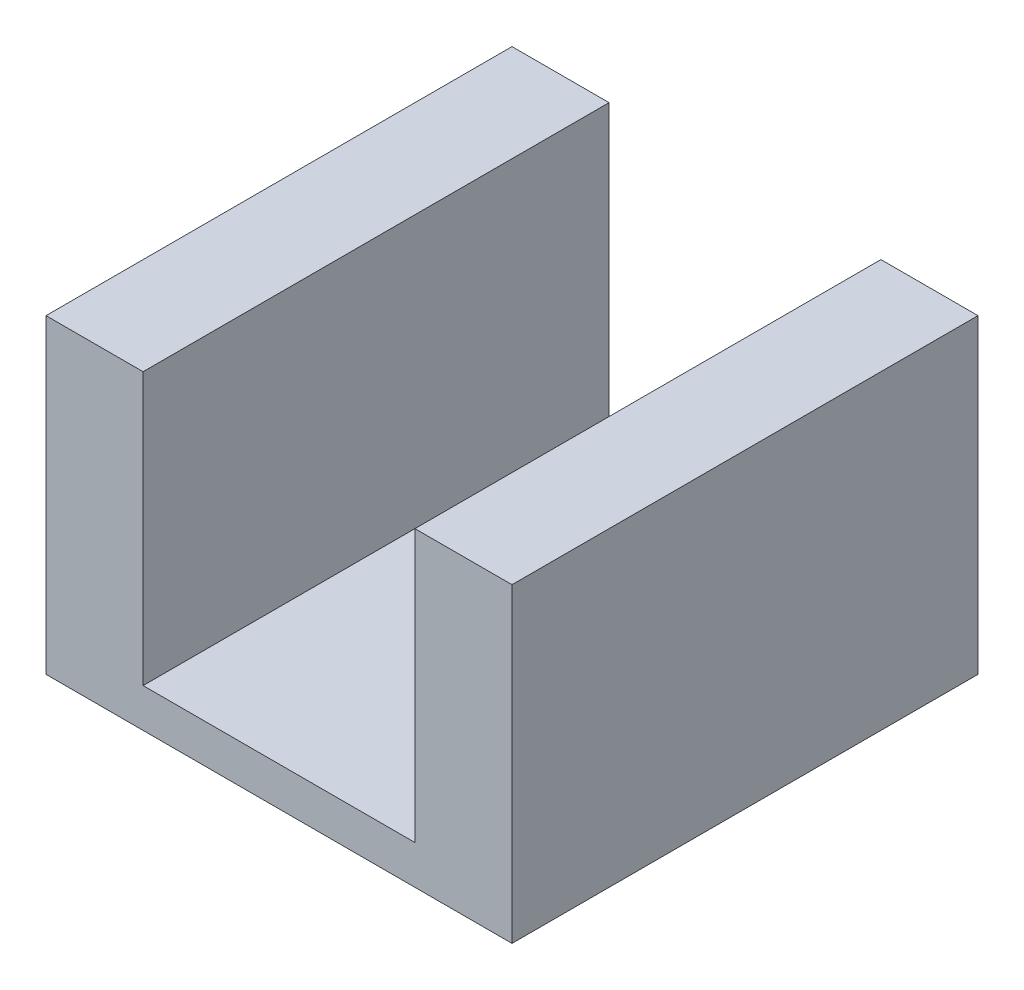
from build123d import *

# Parameters (mm, degrees)
BOSS_EXTRUDE1_DEPTH = 76.2
SKETCH2_R           = 7.9375
CUT_EXTRUDE1_DEPTH  = 7.35


with BuildPart() as part:
    # Sketch1 → Boss-Extrude1 (new body)
    with BuildSketch(Plane.XY):
        Polygon((22.225, 0), (-22.225, 0), (-22.225, 44.45), (-38.1, 44.45), (-38.1, -6.35), (38.1, -6.35), (38.1, 44.45), (22.225, 44.45), align=None)
    extrude(amount=BOSS_EXTRUDE1_DEPTH)

    # Sketch2 → Cut-Extrude1 (cut, through all)
    with BuildSketch(Plane(origin=(0, 0, 0), x_dir=(1, 0, 0), z_dir=(0, 1, 0))):
        with Locations((0, -38.1)):
            Circle(SKETCH2_R)
    extrude(amount=-CUT_EXTRUDE1_DEPTH, mode=Mode.SUBTRACT)


solid = part.part
